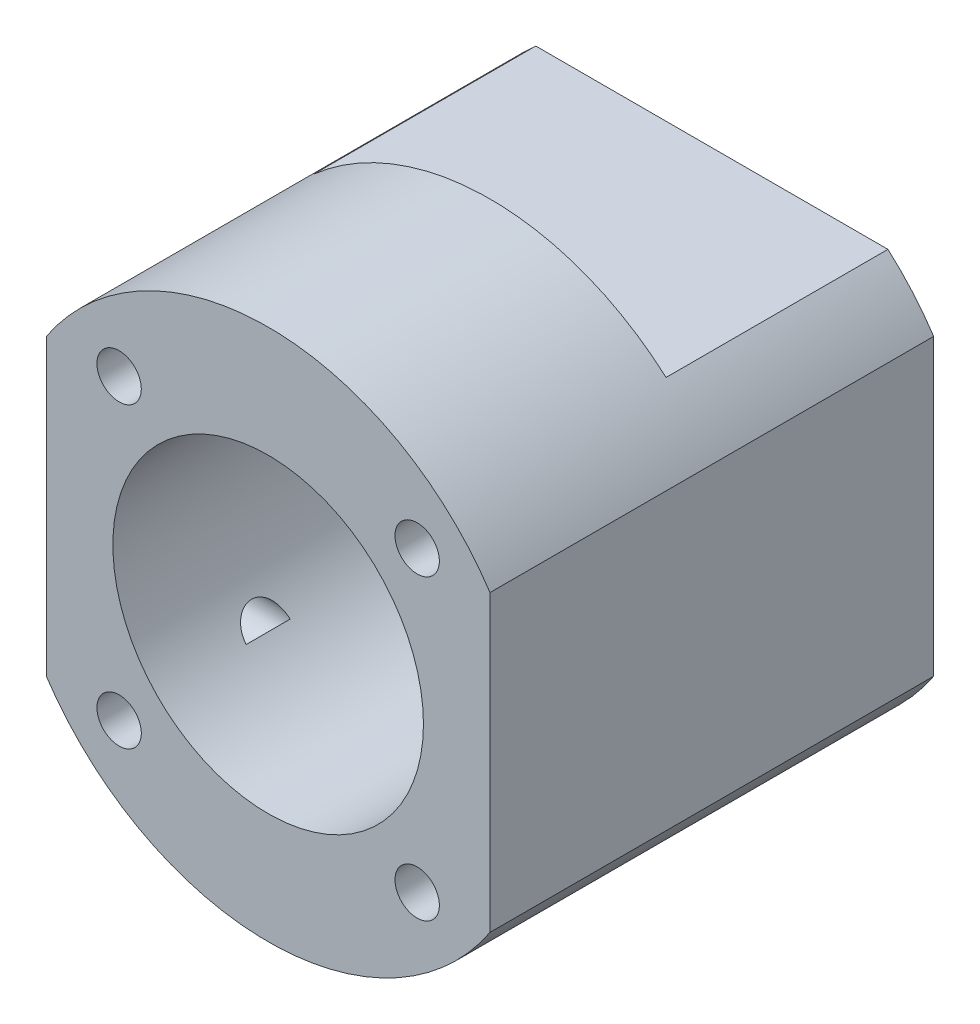
from build123d import *

# Parameters (mm, degrees)
SCHIZZO1_R                   = 14
ESTRUSIONE_ESTRUSIONE1_DEPTH = 40
SCHIZZO4_R                   = 2
TAGLIO_ESTRUSIONE1_DEPTH     = 10
SCHIZZO5_R                   = 2
TAGLIO_ESTRUSIONE2_DEPTH     = 10
SCHIZZO6_W                   = 32.003306677
SCHIZZO6_H                   = 7.880991961
TAGLIO_ESTRUSIONE3_DEPTH     = 20


with BuildPart() as part:
    # Schizzo1 → Estrusione-Estrusione1 (new body)
    with BuildSketch(Plane.XY):
        with BuildLine():
            Line((20, -13.266499161), (20, 13.266499161))
            ThreePointArc((20, 13.266499161), (0, 24), (-20, 13.266499161))
            Line((-20, 13.266499161), (-20, -13.266499161))
            ThreePointArc((-20, -13.266499161), (0, -24), (20, -13.266499161))
        make_face()
        Circle(SCHIZZO1_R, mode=Mode.SUBTRACT)
    extrude(amount=-ESTRUSIONE_ESTRUSIONE1_DEPTH)

    # Schizzo4 → Taglio-Estrusione1 (cut)
    with BuildSketch(Plane.ZY.offset(20)):
        with Locations((-10, 10)):
            Circle(SCHIZZO4_R)
        with Locations((-10, -10)):
            Circle(SCHIZZO4_R)
        with Locations((-30, -10)):
            Circle(SCHIZZO4_R)
        with Locations((-30, 10)):
            Circle(SCHIZZO4_R)
    extrude(amount=-TAGLIO_ESTRUSIONE1_DEPTH, mode=Mode.SUBTRACT)

    # Schizzo5 → Taglio-Estrusione2 (cut)
    with BuildSketch(Plane.XY):
        with Locations((-13.435028843, 13.435028843)):
            Circle(SCHIZZO5_R)
        with Locations((13.435028843, 13.435028843)):
            Circle(SCHIZZO5_R)
        with Locations((13.435028843, -13.435028843)):
            Circle(SCHIZZO5_R)
        with Locations((-13.435028843, -13.435028843)):
            Circle(SCHIZZO5_R)
    extrude(amount=-TAGLIO_ESTRUSIONE2_DEPTH, mode=Mode.SUBTRACT)

    # Schizzo6 → Taglio-Estrusione3 (cut)
    with BuildSketch(Plane(origin=(0, 0, -40), x_dir=(-1, 0, 0), z_dir=(0, 0, -1))):
        with Locations((0.127145472, 21.940495981)):
            Rectangle(SCHIZZO6_W, SCHIZZO6_H)
        with Locations((0.127145472, -21.940495981)):
            Rectangle(SCHIZZO6_W, SCHIZZO6_H)
    extrude(amount=-TAGLIO_ESTRUSIONE3_DEPTH, mode=Mode.SUBTRACT)


solid = part.part
